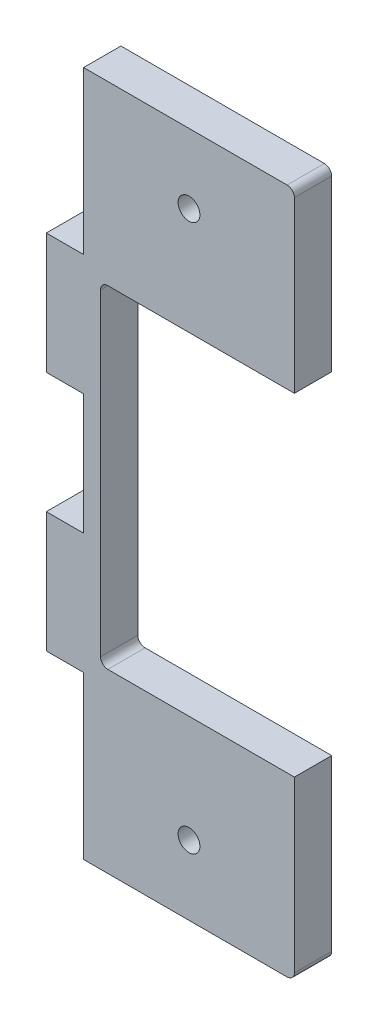
from build123d import *

# Parameters (mm, degrees)
SKETCH1_R           = 1.5
BOSS_EXTRUDE1_DEPTH = 5.13
CUT_EXTRUDE1_REACH  = 7.13


with BuildPart() as part:
    # Sketch1 → Boss-Extrude1 (new body)
    with BuildSketch(Plane.XY):
        with BuildLine():
            Line((-16.470914087, 7.163135174), (-16.470914087, -9.436864826))
            Line((-16.470914087, -9.436864826), (-21.600914087, -9.436864826))
            Line((-21.600914087, -9.436864826), (-21.600914087, -26.036864826))
            Line((-21.600914087, -26.036864826), (-16.470914087, -26.036864826))
            Line((-16.470914087, -26.036864826), (-16.470914087, -48.316864826))
            Line((-16.470914087, -48.316864826), (11.529085913, -48.316864826))
            ThreePointArc((11.529085913, -48.316864826), (12.236192694, -48.023971608), (12.529085913, -47.316864826))
            Line((12.529085913, -47.316864826), (12.529085913, 45.043135174))
            ThreePointArc((12.529085913, 45.043135174), (12.236192694, 45.750241955), (11.529085913, 46.043135174))
            Line((11.529085913, 46.043135174), (-16.470914087, 46.043135174))
            Line((-16.470914087, 46.043135174), (-16.470914087, 23.763135174))
            Line((-16.470914087, 23.763135174), (-21.600914087, 23.763135174))
            Line((-21.600914087, 23.763135174), (-21.600914087, 7.163135174))
            Line((-21.600914087, 7.163135174), (-16.470914087, 7.163135174))
        make_face()
        with Locations((-1.970914087, -38.750864826)):
            Circle(SKETCH1_R, mode=Mode.SUBTRACT)
        with Locations((-1.970914087, 36.477135174)):
            Circle(SKETCH1_R, mode=Mode.SUBTRACT)
    extrude(amount=BOSS_EXTRUDE1_DEPTH)

    # Sketch2 → Cut-Extrude1 (cut, up to next)
    with BuildSketch(Plane.XY.offset(5.13), mode=Mode.PRIVATE) as cut_extrude1_sk1:
        with BuildLine():
            Line((12.529085913, 21.723135174), (-13.140914087, 21.723135174))
            ThreePointArc((-13.140914087, 21.723135174), (-13.848020868, 21.430241955), (-14.140914087, 20.723135174))
            Line((-14.140914087, 20.723135174), (-14.140914087, -22.996864826))
            ThreePointArc((-14.140914087, -22.996864826), (-13.848020868, -23.703971608), (-13.140914087, -23.996864826))
            Line((-13.140914087, -23.996864826), (12.529085913, -23.996864826))
            Line((12.529085913, -23.996864826), (12.529085913, 21.723135174))
        make_face()
    cut_extrude1_tool1 = extrude(cut_extrude1_sk1.sketch, amount=-CUT_EXTRUDE1_REACH, mode=Mode.PRIVATE) & part.part
    add(cut_extrude1_tool1.solids().sort_by_distance((-0.801297, -1.136865, 5.13))[0], mode=Mode.SUBTRACT)


solid = part.part
